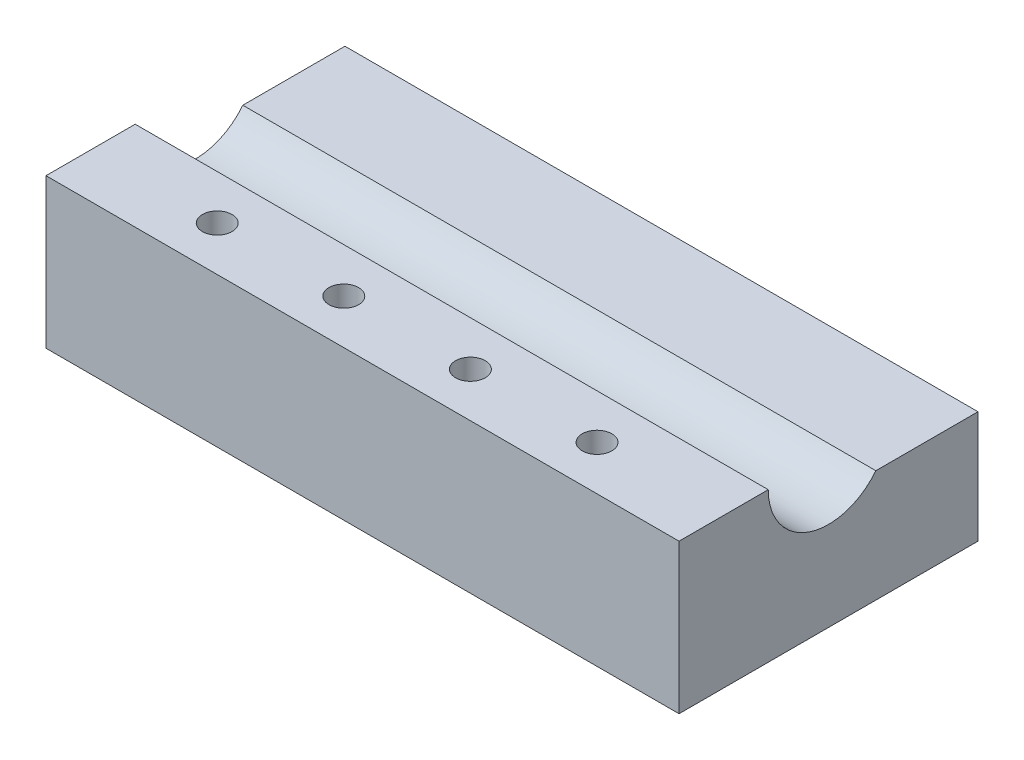
from build123d import *

# Parameters (mm, degrees)
SKETCH1_W                 = 25.41
SKETCH1_H                 = 12
BOSS_EXTRUDE1_DEPTH       = 6
SKETCH2_R                 = 2.42
CUT_EXTRUDE1_DEPTH        = 25.41
SKETCH4_W                 = 4.522418919
SKETCH4_H                 = 1.5
CUT_EXTRUDE2_DEPTH        = 25.41
F_2_56_TAPPED_HOLE1_D     = 2.000000064
F_2_56_TAPPED_HOLE1_DEPTH = 2.649139362
F_2_56_TAPPED_HOLE1_TIP   = 0.600860638
F_0_80_TAPPED_HOLE1_D     = 1.19126
F_0_80_TAPPED_HOLE1_DEPTH = 3.642109389
F_0_80_TAPPED_HOLE1_TIP   = 0.357890611


with BuildPart() as part:
    # Sketch1 → Boss-Extrude1 (new body)
    with BuildSketch(Plane(origin=(0, 0, 0), x_dir=(1, 0, 0), z_dir=(0, 1, 0))):
        with Locations((12.705, 6)):
            Rectangle(SKETCH1_W, SKETCH1_H)
    extrude(amount=BOSS_EXTRUDE1_DEPTH)

    # Sketch2 → Cut-Extrude1 (cut)
    with BuildSketch(Plane.ZY):
        with Locations((-6, 6)):
            Circle(SKETCH2_R)
    extrude(amount=-CUT_EXTRUDE1_DEPTH, mode=Mode.SUBTRACT)

    # Sketch4 → Cut-Extrude2 (cut)
    with BuildSketch(Plane.ZY):
        with Locations((-9.738790541, 5.25)):
            Rectangle(SKETCH4_W, SKETCH4_H)
    extrude(amount=-CUT_EXTRUDE2_DEPTH, mode=Mode.SUBTRACT)

    # #2-56 Tapped Hole1
    with Locations(Plane(origin=(0, 0, 0), x_dir=(-1, 0, 0), z_dir=(0, -1, 0))):
        with Locations((-23.91, 6), (-1.5, 6)):
            Hole(F_2_56_TAPPED_HOLE1_D / 2, depth=F_2_56_TAPPED_HOLE1_DEPTH)
            with Locations((0, 0, -(F_2_56_TAPPED_HOLE1_DEPTH + F_2_56_TAPPED_HOLE1_TIP / 2))):  # 118° drill point
                Cone(0, F_2_56_TAPPED_HOLE1_D / 2, F_2_56_TAPPED_HOLE1_TIP, mode=Mode.SUBTRACT)

    # #0-80 Tapped Hole1
    with Locations(Plane(origin=(0, 6, 0), x_dir=(1, 0, 0), z_dir=(0, 1, 0))):
        with Locations((5.082, 1.79), (10.164, 1.79), (15.246, 1.79), (20.328, 1.79)):
            Hole(F_0_80_TAPPED_HOLE1_D / 2, depth=F_0_80_TAPPED_HOLE1_DEPTH)
            with Locations((0, 0, -(F_0_80_TAPPED_HOLE1_DEPTH + F_0_80_TAPPED_HOLE1_TIP / 2))):  # 118° drill point
                Cone(0, F_0_80_TAPPED_HOLE1_D / 2, F_0_80_TAPPED_HOLE1_TIP, mode=Mode.SUBTRACT)


solid = part.part
